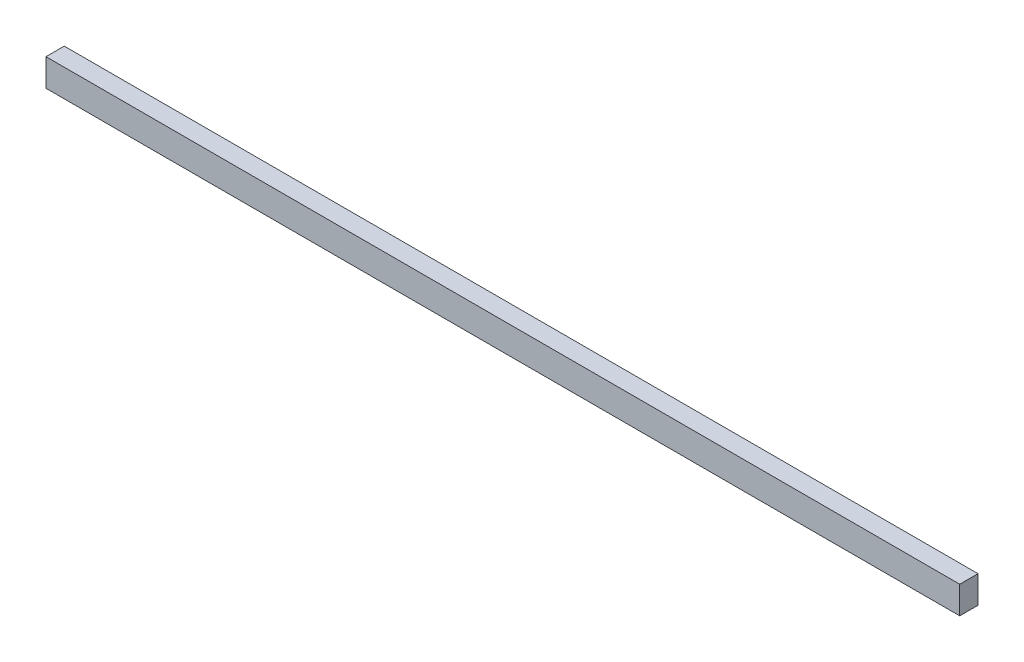
from build123d import *

# Parameters (mm, degrees)
SKETCH_1_W      = 100
SKETCH_1_H      = 2
EXTRUDE_1_DEPTH = 3


with BuildPart() as part:
    # 草图1 → 凸台-拉伸1 (new body)
    with BuildSketch(Plane(origin=(0, 0, 0), x_dir=(1, 0, 0), z_dir=(0, 1, 0))):
        with Locations((54.656061596, -36.406248691)):
            Rectangle(SKETCH_1_W, SKETCH_1_H)
    extrude(amount=EXTRUDE_1_DEPTH)


solid = part.part
